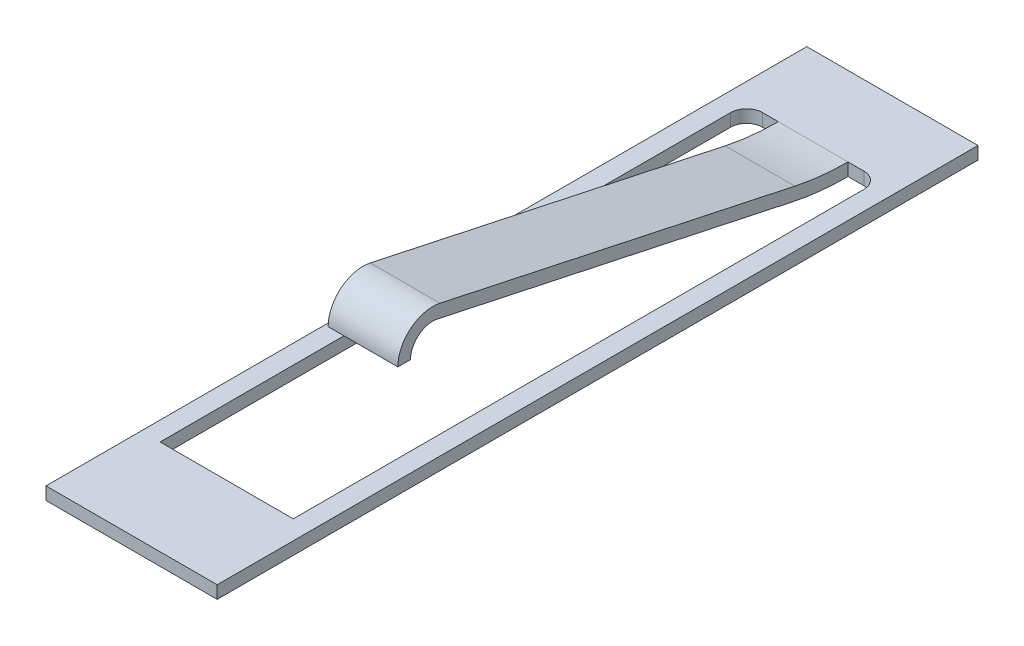
from build123d import *

# Parameters (mm, degrees)
SKETCH1_W           = 2.7
SKETCH1_H           = 12
BOSS_EXTRUDE1_DEPTH = 0.2
CUT_EXTRUDE1_DEPTH  = 1.2
BOSS_EXTRUDE2_START = -0.55
BOSS_EXTRUDE2_DEPTH = 1.1


with BuildPart() as part:
    # Sketch1 → Boss-Extrude1 (new body)
    with BuildSketch(Plane(origin=(0, 0, 0), x_dir=(1, 0, 0), z_dir=(0, 1, 0))):
        Rectangle(SKETCH1_W, SKETCH1_H)
    extrude(amount=BOSS_EXTRUDE1_DEPTH)

    # Sketch2 → Cut-Extrude1 (cut, through all)
    with BuildSketch(Plane(origin=(0, 0, 0), x_dir=(1, 0, 0), z_dir=(0, 1, 0))):
        with BuildLine():
            Line((-1.05, 4.5), (-1.05, -4.5))
            Line((-1.05, -4.5), (1.05, -4.5))
            Line((1.05, -4.5), (1.05, 4.5))
            ThreePointArc((1.05, 4.5), (0.976776695, 4.676776695), (0.8, 4.75))
            Line((0.8, 4.75), (-0.8, 4.75))
            ThreePointArc((-0.8, 4.75), (-0.976776695, 4.676776695), (-1.05, 4.5))
        make_face()
    extrude(amount=CUT_EXTRUDE1_DEPTH, mode=Mode.SUBTRACT)

    # Sketch3 → Boss-Extrude2 (add)
    with BuildSketch(Plane(origin=(0, 0, 0), x_dir=(0, 0, -1), z_dir=(1, 0, 0)).offset(BOSS_EXTRUDE2_START)):
        with BuildLine():
            Line((4.75, 0), (4.75, 0.2))
            ThreePointArc((4.75, 0.2), (4.328691756, 0.222249459), (3.912070453, 0.288750318))
            Line((3.912070453, 0.288750318), (-1.684784687, 1.487796831))
            ThreePointArc((-1.684784687, 1.487796831), (-2.145782864, 1.377708091), (-2.35, 0.95))
            Line((-2.35, 0.95), (-2.15, 0.95))
            ThreePointArc((-2.15, 0.95), (-2.020043641, 1.222177876), (-1.726681165, 1.292234347))
            Line((-1.726681165, 1.292234347), (3.870173975, 0.093187834))
            ThreePointArc((3.870173975, 0.093187834), (4.307626344, 0.023361932), (4.75, 0))
        make_face()
    extrude(amount=BOSS_EXTRUDE2_DEPTH)


solid = part.part
